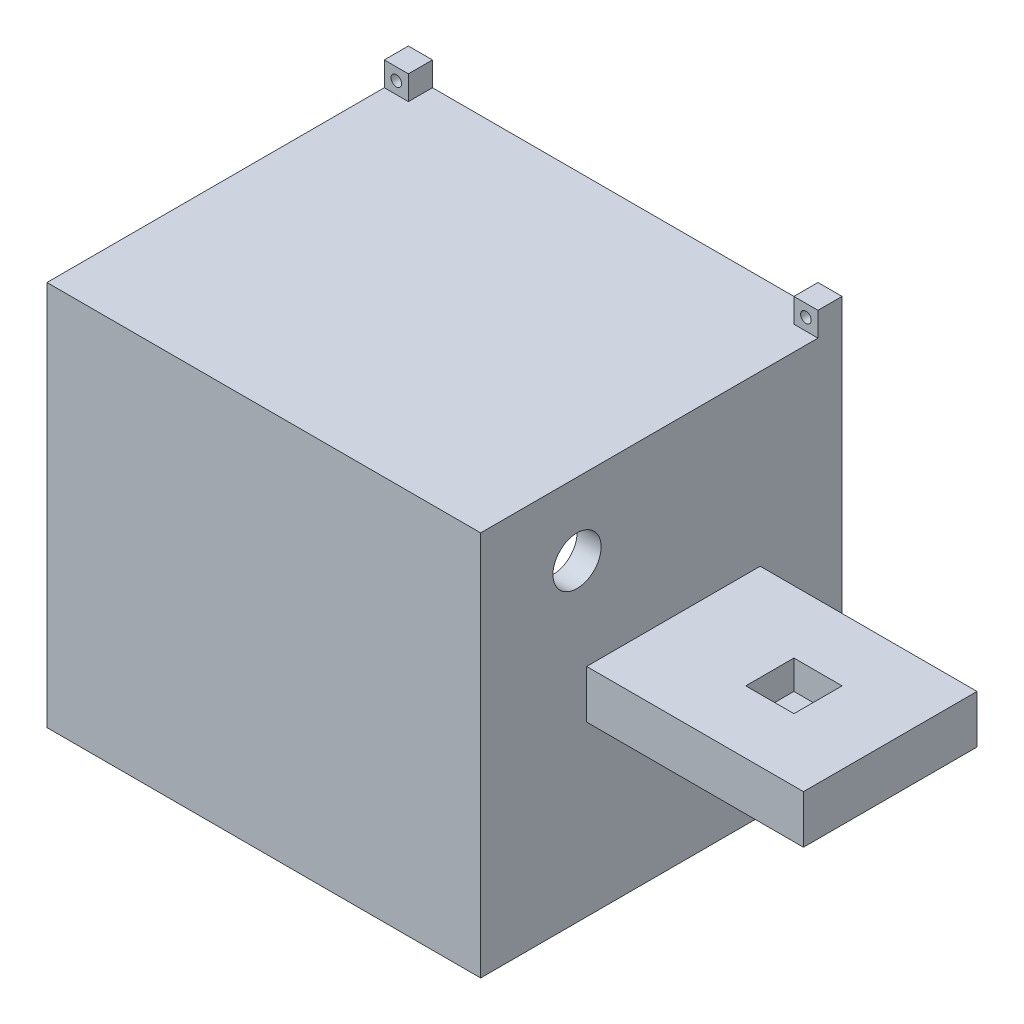
from build123d import *

# Parameters (mm, degrees)
SKETCH_1_W           = 135
SKETCH_1_H           = 80
EXTRUDE_1_DEPTH      = 70
SKETCH_6_W           = 45
SKETCH_6_H           = 70
CUT_EXTRUDE_1_DEPTH  = 35
SKETCH_5_W           = 45
SKETCH_5_H           = 70
CUT_EXTRUDE_2_DEPTH  = 35
SKETCH_7_W           = 80
SKETCH_7_H           = 70
CUT_EXTRUDE_3_DEPTH  = 75
SKETCH_8_W           = 87.8
SKETCH_8_H           = 77.8
SKETCH_8_W_2         = 82.2
SKETCH_8_H_2         = 72.2
CUT_EXTRUDE_4_DEPTH  = 10
SKETCH_9_R           = 5
CUT_EXTRUDE_5_DEPTH  = 32.4
SKETCH_10_W          = 21.5
SKETCH_10_H          = 15
CUT_EXTRUDE_6_DEPTH  = 10
SKETCH_12_W          = 16.99068276
SKETCH_12_H          = 10
CUT_EXTRUDE_7_DEPTH  = 45
CUT_EXTRUDE_8_DEPTH  = 3
SKETCH_15_W          = 10
SKETCH_15_H          = 10
CUT_EXTRUDE_9_DEPTH  = 6
SKETCH_17_R          = 1.095275866
CUT_EXTRUDE_11_DEPTH = 7
SKETCH_18_W          = 5
SKETCH_18_H          = 5
SKETCH_18_R          = 1.1
EXTRUDE_2_DEPTH      = 5
SKETCH_19_W          = 90
SKETCH_19_H          = 80
EXTRUDE_3_DEPTH      = 5


with BuildPart() as part:
    # 草圖1 → 填料-伸長1 (new body)
    with BuildSketch(Plane.XY):
        with Locations((-8.008902174, 5.58988764)):
            Rectangle(SKETCH_1_W, SKETCH_1_H)
    extrude(amount=EXTRUDE_1_DEPTH)

    # 草圖6 → 除料-伸長1 (cut)
    with BuildSketch(Plane(origin=(0, 45.58988764, 0), x_dir=(1, 0, 0), z_dir=(0, 1, 0))):
        with Locations((36.991097826, -35)):
            Rectangle(SKETCH_6_W, SKETCH_6_H)
    extrude(amount=-CUT_EXTRUDE_1_DEPTH, mode=Mode.SUBTRACT)

    # 草圖5 → 除料-伸長2 (cut)
    with BuildSketch(Plane.XZ.offset(34.41011236)):
        with Locations((36.991097826, 35)):
            Rectangle(SKETCH_5_W, SKETCH_5_H)
    extrude(amount=-CUT_EXTRUDE_2_DEPTH, mode=Mode.SUBTRACT)

    # 草圖7 → 除料-伸長3 (cut)
    with BuildSketch(Plane.XY):
        with Locations((-30.508902174, 5.58988764)):
            Rectangle(SKETCH_7_W, SKETCH_7_H)
    extrude(amount=CUT_EXTRUDE_3_DEPTH, mode=Mode.SUBTRACT)

    # 草圖8 → 除料-伸長4 (cut)
    with BuildSketch(Plane(origin=(0, 0, 0), x_dir=(-1, 0, 0), z_dir=(0, 0, -1))):
        with Locations((30.508902174, 5.58988764)):
            Rectangle(SKETCH_8_W, SKETCH_8_H)
        with Locations((30.508902174, 5.58988764)):
            Rectangle(SKETCH_8_W_2, SKETCH_8_H_2, mode=Mode.SUBTRACT)
    extrude(amount=-CUT_EXTRUDE_4_DEPTH, mode=Mode.SUBTRACT)

    # 草圖9 → 除料-伸長5 (cut)
    with BuildSketch(Plane(origin=(14.491097826, 0, 0), x_dir=(0, 0, -1), z_dir=(1, 0, 0))):
        with Locations((-55, 30.58988764)):
            Circle(SKETCH_9_R)
        with Locations((-20, -19.41011236)):
            Circle(SKETCH_9_R)
    extrude(amount=-CUT_EXTRUDE_5_DEPTH, mode=Mode.SUBTRACT)

    # 草圖10 → 除料-伸長6 (cut)
    with BuildSketch(Plane(origin=(0, -34.41011236, 0), x_dir=(-1, 0, 0), z_dir=(0, -1, 0))):
        with Locations((24.758902174, -18.5)):
            Rectangle(SKETCH_10_W, SKETCH_10_H)
    extrude(amount=-CUT_EXTRUDE_6_DEPTH, mode=Mode.SUBTRACT)

    # 草圖12 → 除料-伸長7 (cut)
    with BuildSketch(Plane(origin=(14.491097826, 0, 0), x_dir=(0, 0, -1), z_dir=(1, 0, 0))):
        with Locations((-61.50465862, 5.58988764)):
            Rectangle(SKETCH_12_W, SKETCH_12_H)
        with Locations((-8.49534138, 5.58988764)):
            Rectangle(SKETCH_12_W, SKETCH_12_H)
    extrude(amount=CUT_EXTRUDE_7_DEPTH, mode=Mode.SUBTRACT)

    # 草圖14 → 除料-伸長8 (cut)
    with BuildSketch(Plane(origin=(0, 0.58988764, 0), x_dir=(-1, 0, 0), z_dir=(0, -1, 0))):
        with BuildLine():
            Line((-38.009101008, -30.10282789), (-21.517914827, -33.5))
            ThreePointArc((-21.517914827, -33.5), (-20.017914827, -35), (-21.517914827, -36.5))
            Line((-21.517914827, -36.5), (-38.009101008, -39.89717211))
            ThreePointArc((-38.009101008, -39.89717211), (-39.017914827, -40), (-40.026728646, -39.89717211))
            Line((-40.026728646, -39.89717211), (-56.517914827, -36.5))
            ThreePointArc((-56.517914827, -36.5), (-58.017914827, -35), (-56.517914827, -33.5))
            Line((-56.517914827, -33.5), (-40.026728646, -30.10282789))
            ThreePointArc((-40.026728646, -30.10282789), (-39.017914827, -30), (-38.009101008, -30.10282789))
        make_face()
    extrude(amount=-CUT_EXTRUDE_8_DEPTH, mode=Mode.SUBTRACT)

    # 草圖15 → 除料-伸長9 (cut)
    with BuildSketch(Plane(origin=(0, 10.58988764, 0), x_dir=(1, 0, 0), z_dir=(0, 1, 0))):
        with Locations((39.491097826, -34.99068276)):
            Rectangle(SKETCH_15_W, SKETCH_15_H)
    extrude(amount=-CUT_EXTRUDE_9_DEPTH, mode=Mode.SUBTRACT)

    # 草圖17 → 除料-伸長11 (cut)
    with BuildSketch(Plane(origin=(0, 0.58988764, 0), x_dir=(-1, 0, 0), z_dir=(0, -1, 0))):
        with Locations((-39.017914827, -35)):
            Circle(SKETCH_17_R)
    extrude(amount=-CUT_EXTRUDE_11_DEPTH, mode=Mode.SUBTRACT)

    # 草圖18 → 填料-伸長2 (add)
    with BuildSketch(Plane.XY):
        with Locations((11.991097826, 48.08988764)):
            Rectangle(SKETCH_18_W, SKETCH_18_H)
        with Locations((11.991097826, 48.08988764)):
            Circle(SKETCH_18_R, mode=Mode.SUBTRACT)
        with Locations((-73.008902174, 48.08988764)):
            Rectangle(SKETCH_18_W, SKETCH_18_H)
        with Locations((-73.008902174, 48.08988764)):
            Circle(SKETCH_18_R, mode=Mode.SUBTRACT)
        with Locations((-73.008902174, -36.91011236)):
            Rectangle(SKETCH_18_W, SKETCH_18_H)
        with Locations((-73.008902174, -36.91011236)):
            Circle(SKETCH_18_R, mode=Mode.SUBTRACT)
        with Locations((11.991097826, -36.91011236)):
            Rectangle(SKETCH_18_W, SKETCH_18_H)
        with Locations((11.991097826, -36.91011236)):
            Circle(SKETCH_18_R, mode=Mode.SUBTRACT)
    extrude(amount=EXTRUDE_2_DEPTH)

    # 草圖19 → 填料-伸長3 (add)
    with BuildSketch(Plane.XY.offset(70)):
        with Locations((-30.508902174, 5.58988764)):
            Rectangle(SKETCH_19_W, SKETCH_19_H)
    extrude(amount=EXTRUDE_3_DEPTH)


solid = part.part
